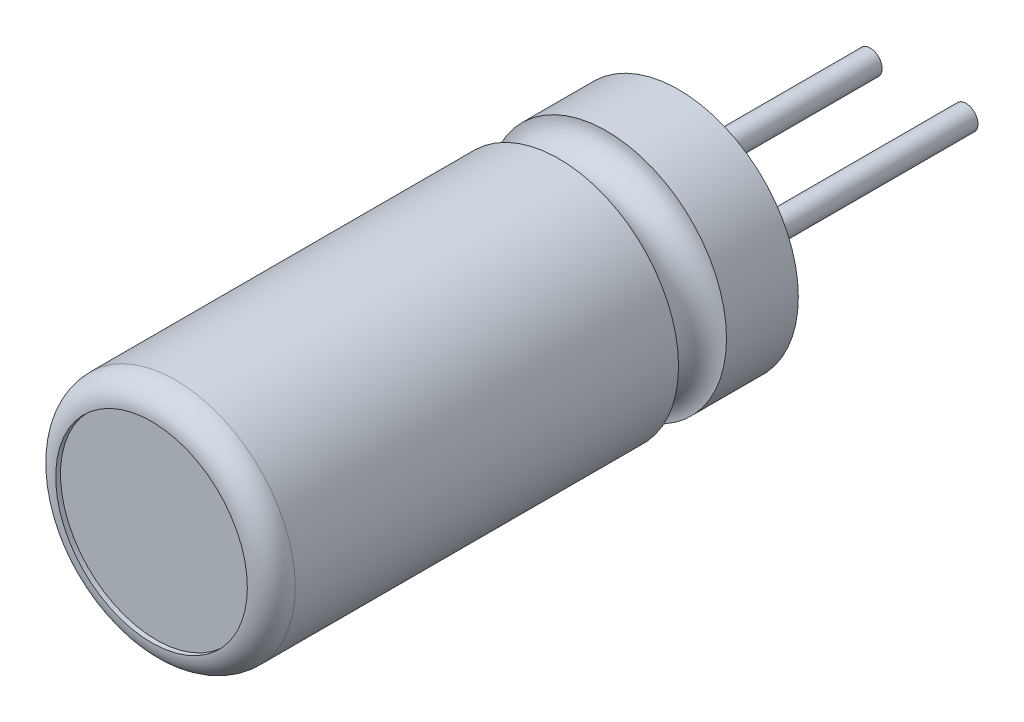
from build123d import *

# Parameters (mm, degrees)
SKETCH3_R           = 2
CUT_EXTRUDE1_DEPTH  = 0.1
SKETCH4_R           = 0.25
BOSS_EXTRUDE1_DEPTH = 5


with BuildPart() as part:
    # Sketch2 → Base-Revolve (revolve)
    with BuildSketch(Plane(origin=(0, 0, 0), x_dir=(0, 0, -1), z_dir=(1, 0, 0))):
        with BuildLine():
            Line((0, 0), (0, 2.5))
            Line((0, 2.5), (-1.5, 2.5))
            ThreePointArc((-1.5, 2.5), (-2, 2), (-2.5, 2.5))
            Line((-2.5, 2.5), (-10.5, 2.5))
            ThreePointArc((-10.5, 2.5), (-10.853553391, 2.353553391), (-11, 2))
            Line((-11, 2), (-11, 0))
            Line((-11, 0), (0, 0))
        make_face()
    revolve(axis=Axis((0, 0, 11), (0, 0, -1)))

    # Sketch3 → Cut-Extrude1 (cut)
    with BuildSketch(Plane.XY.offset(11)):
        Circle(SKETCH3_R)
    extrude(amount=-CUT_EXTRUDE1_DEPTH, mode=Mode.SUBTRACT)

    # Sketch4 → Boss-Extrude1 (add)
    with BuildSketch(Plane(origin=(0, 0, 0), x_dir=(-1, 0, 0), z_dir=(0, 0, -1))):
        with Locations((1, 0)):
            Circle(SKETCH4_R)
        with Locations((-1, 0)):
            Circle(SKETCH4_R)
    extrude(amount=BOSS_EXTRUDE1_DEPTH)


solid = part.part
